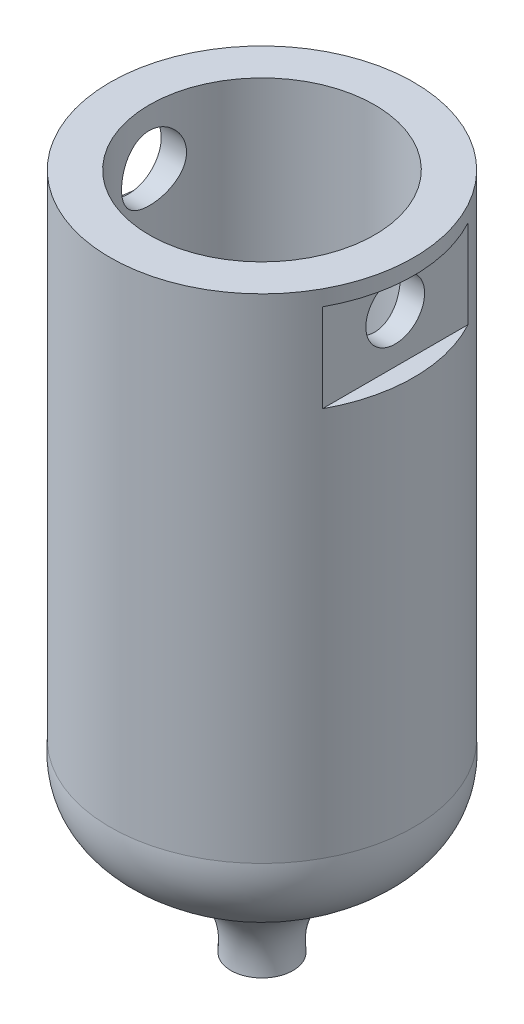
from build123d import *

# Parameters (mm, degrees)
CUT_EXTRUDE1_DEPTH      = 20.373272444
CUT_EXTRUDE1_DEPTH_BACK = 5
SKETCH3_R               = 0.75
SKETCH5_R               = 0.830043706
CUT_EXTRUDE3_DEPTH      = 5
CUT_EXTRUDE4_DEPTH      = 10
CUT_EXTRUDE4_DEPTH_BACK = 10
SKETCH6_W               = 0.475158235
SKETCH6_H               = 2.253950387
SKETCH6_W_2             = 0.475158234


with BuildPart() as part:
    # Sketch1 → Revolve1 (revolve)
    with BuildSketch(Plane.XY):
        with BuildLine():
            Line((0, 0), (1, 0))
            Line((1, 0), (1, -12))
            Line((1, -12), (1, -12.602750297))
            add(Edge.make_bspline(
                [(1, -12.602750297), (0.79843866, -14.189468734), (4.052548494, -14.158592974), (3.356440043, -16.677675858), (3.45632985, -17.31657115)],
                knots=[0, 0, 0, 0, 0.610593848, 1, 1, 1, 1], degree=3))
            Line((3.45632985, -17.31657115), (3.084044258, -17.31657115))
            add(Edge.make_bspline(
                [(0, -12.602750297), (-0.217127131, -15.249179965), (3.341761348, -14.727809166), (3.084044258, -17.31657115)],
                knots=[0, 0, 0, 0, 1, 1, 1, 1], degree=3))
            Line((0, -12.602750297), (0, -12))
            Line((0, -12), (0, 0))
        make_face()
    revolve(axis=Axis((3.879111396, 0, 0), (0, -1, 0)))

    # Sketch3 → Cut-Extrude1 (cut, two sides: drawn at the far end of the back side and taken through both)
    with BuildSketch(Plane(origin=(7.7582228, 0, 0), x_dir=(0, 0, -1), z_dir=(1, 0, 0)).offset(-CUT_EXTRUDE1_DEPTH_BACK)):
        with Locations((0, -1.4)):
            Circle(SKETCH3_R)
    extrude(amount=CUT_EXTRUDE1_DEPTH + CUT_EXTRUDE1_DEPTH_BACK, mode=Mode.SUBTRACT)

    # Sketch5 → Cut-Extrude3 (cut)
    with BuildSketch(Plane(origin=(-0.0208886, 0, 0), x_dir=(0, 0, -1), z_dir=(1, 0, 0))):
        with Locations((0, -1.4)):
            Circle(SKETCH5_R)
    extrude(amount=CUT_EXTRUDE3_DEPTH, mode=Mode.SUBTRACT)

    # Sketch6 → Cut-Extrude4 (cut, two sides: drawn at the far end of the back side and taken through both)
    with BuildSketch(Plane.XY.offset(-CUT_EXTRUDE4_DEPTH_BACK)):
        with Locations((0.237579118, -1.525266711)):
            Rectangle(SKETCH6_W, SKETCH6_H)
        with Locations((7.520643674, -1.525266711)):
            Rectangle(SKETCH6_W_2, SKETCH6_H)
    extrude(amount=CUT_EXTRUDE4_DEPTH + CUT_EXTRUDE4_DEPTH_BACK, mode=Mode.SUBTRACT)


solid = part.part
